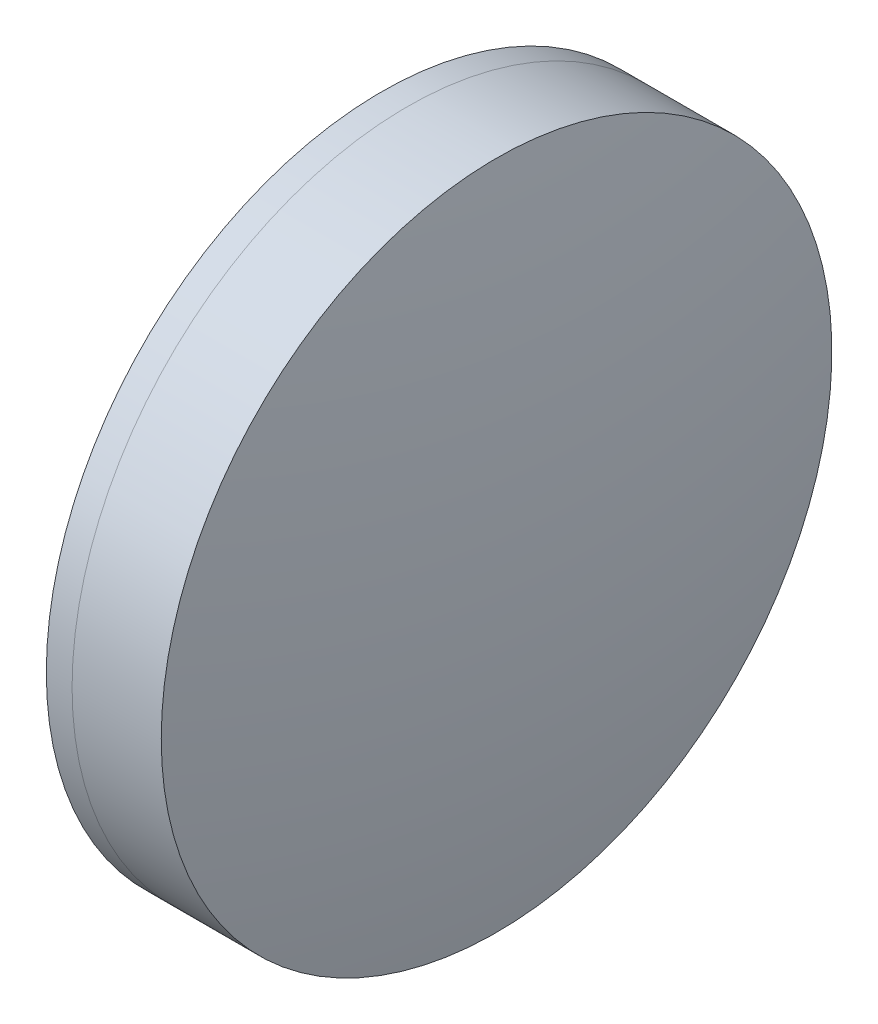
from build123d import *


with BuildPart() as part:
    # 草图1 one side → 旋转1 (revolve)
    with BuildSketch(Plane(origin=(0, 0, 0), x_dir=(1, 0, 0), z_dir=(0, 1, 0)), mode=Mode.PRIVATE) as revolve_1_sk:
        with BuildLine():
            ThreePointArc((220.773885835, 25), (217.052163, 12.745438125), (215.795455157, 0))
            Line((215.795455157, 0), (229.685455157, 0))
            ThreePointArc((229.685455157, 0), (227.904863713, 12.979515623), (222.694653829, 25))
            Line((222.694653829, 25), (220.773885835, 25))
        make_face()
    revolve(revolve_1_sk.sketch.rotate(Axis((124.523309526, 0, 0), (1, 0, 0)), 180), axis=Axis((124.523309526, 0, 0), (1, 0, 0)))  # turned: the seam where the file's is


with BuildPart() as body_2:
    # 草图2 one side → 旋转3 (revolve)
    with BuildSketch(Plane(origin=(0, 0, 0), x_dir=(1, 0, 0), z_dir=(0, 1, 0)), mode=Mode.PRIVATE) as revolve_3_sk:
        with BuildLine():
            Line((229.343243301, 25), (222.694653829, 25))
            ThreePointArc((222.694653829, 25), (227.904863713, 12.979515623), (229.685455157, 0))
            Line((229.685455157, 0), (231.685455157, 0))
            ThreePointArc((231.685455157, 0), (231.098622875, 12.554739706), (229.343243301, 25))
        make_face()
    revolve(revolve_3_sk.sketch.rotate(Axis((-0.551919993, 0, 0), (1, 0, 0)), 180), axis=Axis((-0.551919993, 0, 0), (1, 0, 0)))  # turned: the seam where the file's is


solid = Compound([part.part, body_2.part])
